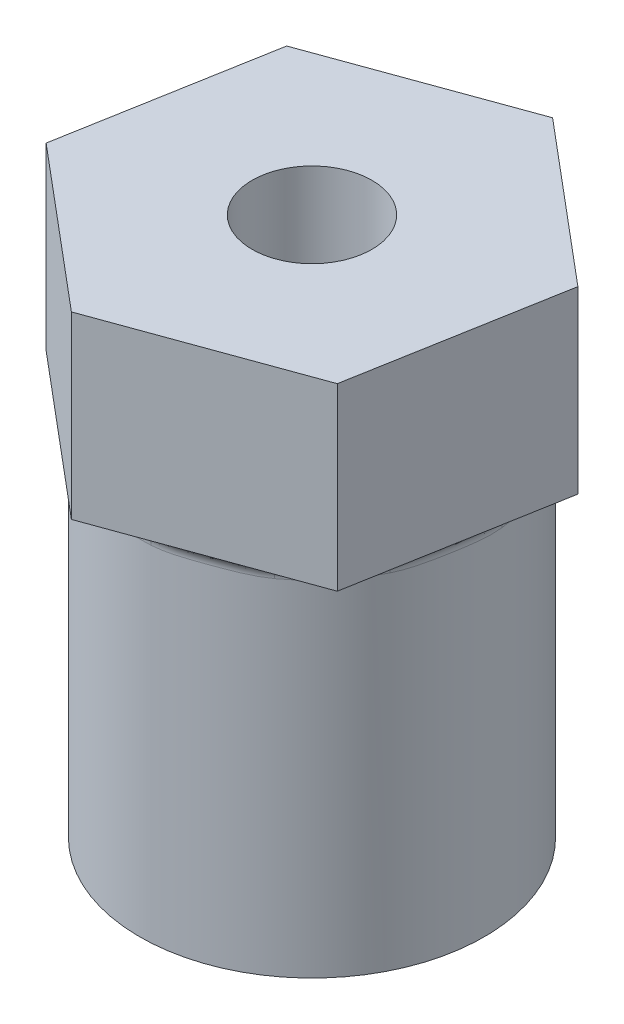
from build123d import *

# Parameters (mm, degrees)
BOSS_EXTRUDE1_DEPTH = 6
SKETCH2_R           = 5.75
BOSS_EXTRUDE2_DEPTH = 12
FILLET1_R           = 0.5
SKETCH3_R           = 2
CUT_EXTRUDE1_DEPTH  = 19.0000001


with BuildPart() as part:
    # Sketch1 → Boss-Extrude1 (new body)
    with BuildSketch(Plane(origin=(0, 0, 0), x_dir=(1, 0, 0), z_dir=(0, 1, 0))):
        Polygon((1.209770832, 6.821763301), (-5.302934901, 4.458573924), (-6.512705733, -2.363189377), (-1.209770832, -6.821763301), (5.302934901, -4.458573924), (6.512705733, 2.363189377), align=None)
    extrude(amount=BOSS_EXTRUDE1_DEPTH)

    # Sketch2 → Boss-Extrude2 (add)
    with BuildSketch(Plane(origin=(0, 0, 0), x_dir=(-1, 0, 0), z_dir=(0, -1, 0))):
        Circle(SKETCH2_R)
    extrude(amount=BOSS_EXTRUDE2_DEPTH)

    # Fillet1
    fillet1_edges = [part.edges().sort_by_distance(p)[0] for p in [
        (5.75, 0, 0),
    ]]
    fillet(fillet1_edges, radius=FILLET1_R)

    # Sketch3 → Cut-Extrude1 (cut, through all)
    with BuildSketch(Plane(origin=(0, -12, 0), x_dir=(-1, 0, 0), z_dir=(0, -1, 0))):
        Circle(SKETCH3_R)
    extrude(amount=-CUT_EXTRUDE1_DEPTH, mode=Mode.SUBTRACT)


solid = part.part
